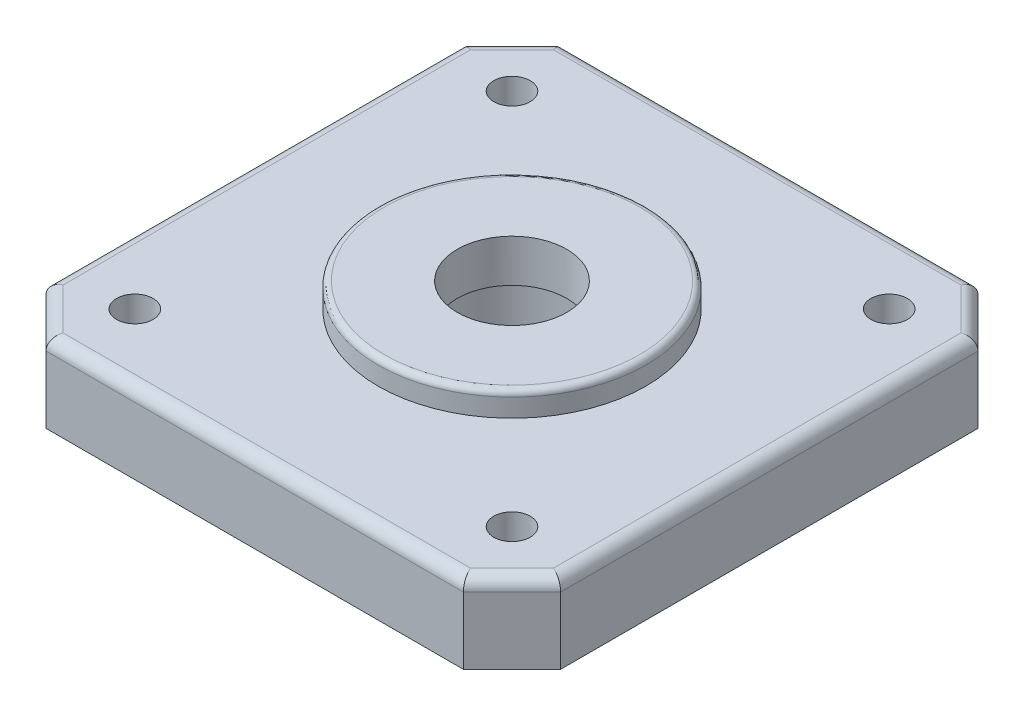
from build123d import *

# Parameters (mm, degrees)
BOSS_EXTRUDE1_DEPTH = 6.5
SKETCH2_R           = 11
BOSS_EXTRUDE2_DEPTH = 2
SKETCH3_R           = 1.5
CUT_EXTRUDE2_DEPTH  = 6.5
SKETCH4_R           = 4.5
CUT_EXTRUDE3_DEPTH  = 8.5
SKETCH5_R           = 5.5
CUT_EXTRUDE4_DEPTH  = 5
FILLET1_R           = 1
FILLET2_R           = 0.5


with BuildPart() as part:
    # Sketch1 → Boss-Extrude1 (new body)
    with BuildSketch(Plane(origin=(0, 0, 0), x_dir=(1, 0, 0), z_dir=(0, 1, 0))):
        Polygon((-21.15, 17.15), (-17.15, 21.15), (17.15, 21.15), (21.15, 17.15), (21.15, -17.15), (17.15, -21.15), (-17.15, -21.15), (-21.15, -17.15), align=None)
    extrude(amount=BOSS_EXTRUDE1_DEPTH)

    # Sketch2 → Boss-Extrude2 (add)
    with BuildSketch(Plane(origin=(0, 6.5, 0), x_dir=(1, 0, 0), z_dir=(0, 1, 0))):
        Circle(SKETCH2_R)
    extrude(amount=BOSS_EXTRUDE2_DEPTH)

    # Sketch3 → Cut-Extrude2 (cut)
    with BuildSketch(Plane(origin=(0, 6.5, 0), x_dir=(1, 0, 0), z_dir=(0, 1, 0))):
        with Locations((-15.5, 15.5)):
            Circle(SKETCH3_R)
        with Locations((15.5, 15.5)):
            Circle(SKETCH3_R)
        with Locations((-15.5, -15.5)):
            Circle(SKETCH3_R)
        with Locations((15.5, -15.5)):
            Circle(SKETCH3_R)
    extrude(amount=-CUT_EXTRUDE2_DEPTH, mode=Mode.SUBTRACT)

    # Sketch4 → Cut-Extrude3 (cut)
    with BuildSketch(Plane(origin=(0, 8.5, 0), x_dir=(1, 0, 0), z_dir=(0, 1, 0))):
        Circle(SKETCH4_R)
    extrude(amount=-CUT_EXTRUDE3_DEPTH, mode=Mode.SUBTRACT)

    # Sketch5 → Cut-Extrude4 (cut)
    with BuildSketch(Plane.XZ):
        Circle(SKETCH5_R)
    extrude(amount=-CUT_EXTRUDE4_DEPTH, mode=Mode.SUBTRACT)

    # Fillet1
    fillet1_edges = [part.edges().sort_by_distance(p)[0] for p in [
        (-21.15, 6.5, 0),
        (-19.15, 6.5, 19.15),
        (0, 6.5, 21.15),
        (19.15, 6.5, 19.15),
        (21.15, 6.5, 0),
        (19.15, 6.5, -19.15),
        (0, 6.5, -21.15),
        (-19.15, 6.5, -19.15),
    ]]
    fillet(fillet1_edges, radius=FILLET1_R)

    # Fillet2
    fillet2_edges = [part.edges().sort_by_distance(p)[0] for p in [
        (-11, 8.5, 0),
    ]]
    fillet(fillet2_edges, radius=FILLET2_R)


solid = part.part
